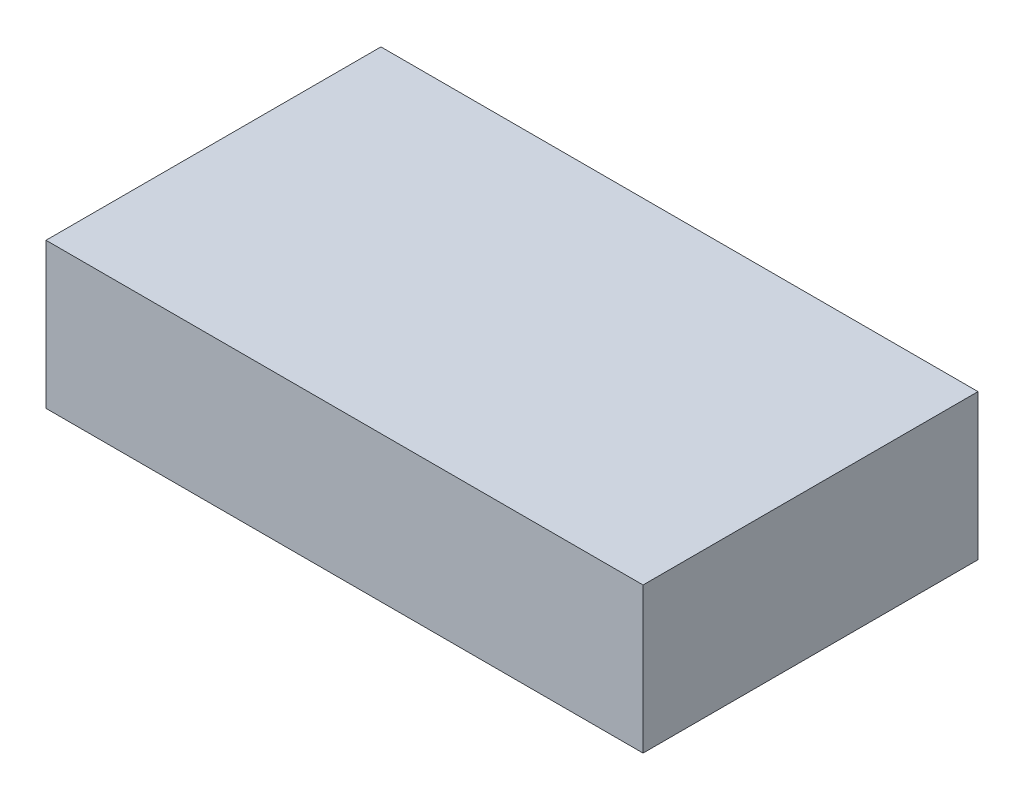
from build123d import *

# Parameters (mm, degrees)
SKETCH1_W                = 205
SKETCH1_H                = 115
BOSS_EXTRUDE1_DEPTH      = 50
M4_CLEARANCE_HOLE1_D     = 4.5
M4_CLEARANCE_HOLE1_DEPTH = 5
M4_CLEARANCE_HOLE1_TIP   = 1.351936393


with BuildPart() as part:
    # Sketch1 → Boss-Extrude1 (new body)
    with BuildSketch(Plane(origin=(0, 0, 0), x_dir=(1, 0, 0), z_dir=(0, 1, 0))):
        Rectangle(SKETCH1_W, SKETCH1_H)
    extrude(amount=BOSS_EXTRUDE1_DEPTH)

    # M4 Clearance Hole1
    with Locations(Plane(origin=(0, 0, 0), x_dir=(-1, 0, 0), z_dir=(0, -1, 0))):
        with Locations((70, -25), (-70, -25), (-70, 25), (70, 25)):
            Hole(M4_CLEARANCE_HOLE1_D / 2, depth=M4_CLEARANCE_HOLE1_DEPTH)
            with Locations((0, 0, -(M4_CLEARANCE_HOLE1_DEPTH + M4_CLEARANCE_HOLE1_TIP / 2))):  # 118° drill point
                Cone(0, M4_CLEARANCE_HOLE1_D / 2, M4_CLEARANCE_HOLE1_TIP, mode=Mode.SUBTRACT)


solid = part.part
